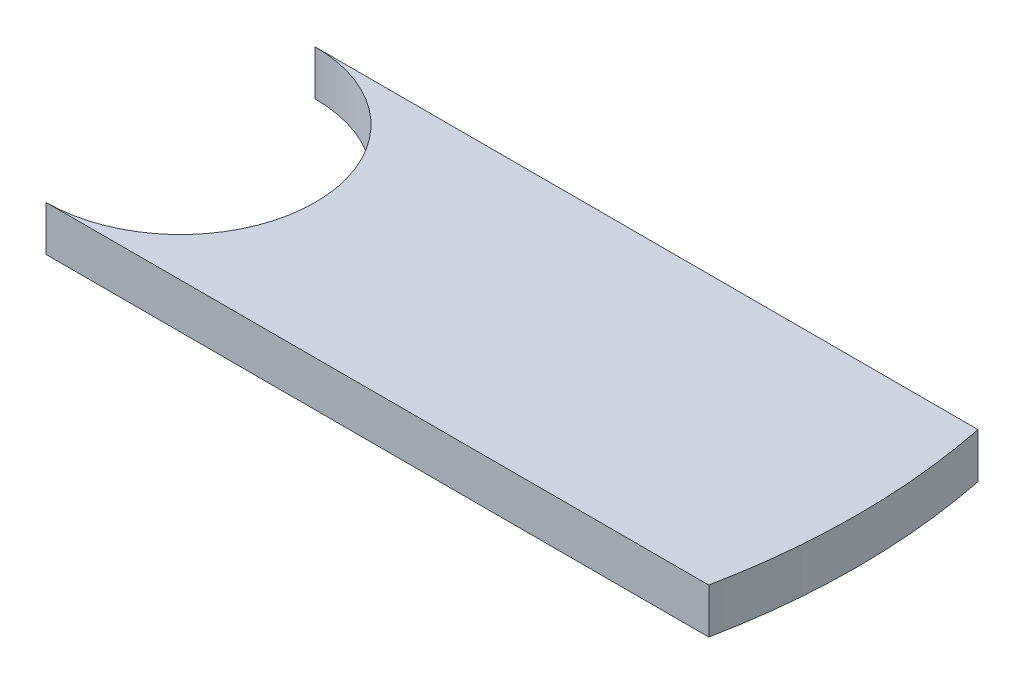
from build123d import *

# Parameters (mm, degrees)
BOSS_EXTRUDE1_DEPTH = 8.9


with BuildPart() as part:
    # Sketch1 → Boss-Extrude1 (new body)
    with BuildSketch(Plane(origin=(0, 0, 0), x_dir=(1, 0, 0), z_dir=(0, 1, 0))):
        with BuildLine():
            Line((0, -26.575), (130.828205579, -26.575))
            ThreePointArc((130.828205579, -26.575), (132.830371988, -13.354485299), (133.5, 0))
            ThreePointArc((133.5, 0), (132.830371988, 13.354485299), (130.828205579, 26.575))
            Line((130.828205579, 26.575), (0, 26.575))
            ThreePointArc((0, 26.575), (26.575, 0), (0, -26.575))
        make_face()
    extrude(amount=BOSS_EXTRUDE1_DEPTH)


solid = part.part
